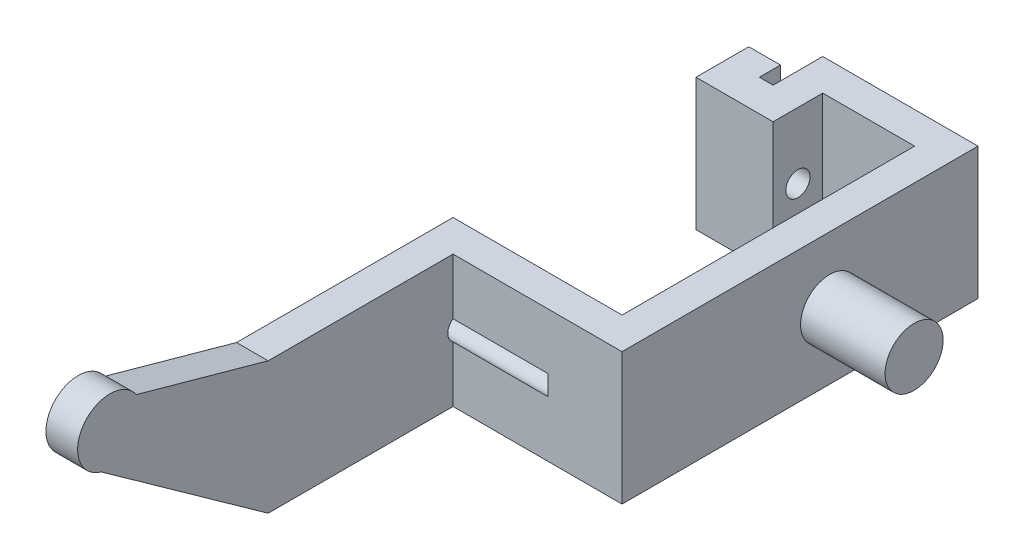
from build123d import *
from build123d.topology import SkipClean

# Parameters (mm, degrees)
EXTRUDE_1_DEPTH     = 12.5
SKETCH_2_R          = 1.15
CUT_EXTRUDE_1_DEPTH = 12
SKETCH_3_R          = 2.75
EXTRUDE_2_DEPTH     = 8
EXTRUDE_3_DEPTH     = 3
CUT_EXTRUDE_5_DEPTH = 3


with BuildPart() as part:
    # 草图1 → 凸台-拉伸1 (new body)
    with BuildSketch(Plane(origin=(0, 0, 0), x_dir=(1, 0, 0), z_dir=(0, 1, 0))):
        Polygon((0, 5), (0, 0), (7.3, 0), (7.3, 3), (7.3, 4.7), (16, 4.7), (16, 3), (16, 0), (16, -23), (0, -23), (0, -61), (3, -61), (3, -26), (19, -26), (19, 3), (19, 7.7), (4.3, 7.7), (4.3, 3), (3, 3), (3, 5), align=None)
    extrude(amount=EXTRUDE_1_DEPTH)

    # 草图2 → 切除-拉伸1 (cut)
    with BuildSketch(Plane.ZY):
        with Locations((25.35, 6.25)):
            Circle(SKETCH_2_R)
        with Locations((-2.35, 6.25)):
            Circle(SKETCH_2_R)
    extrude(amount=-CUT_EXTRUDE_1_DEPTH, mode=Mode.SUBTRACT)

    # 草图3 → 凸台-拉伸2 (add)
    with BuildSketch(Plane(origin=(19, 0, 0), x_dir=(0, 0, -1), z_dir=(1, 0, 0))):
        with Locations((-6.35, 6.25)):
            Circle(SKETCH_3_R)
    extrude(amount=EXTRUDE_2_DEPTH)

    # 草图4 → 凸台-拉伸3 (add)
    with BuildSketch(Plane(origin=(3, 0, 0), x_dir=(0, 0, -1), z_dir=(1, 0, 0))):
        with BuildLine():
            Line((-43.5, 12.5), (-55.974372634, 15.968285379))
            ThreePointArc((-55.974372634, 15.968285379), (-60.221329006, 16.746956372), (-61, 12.5))
            Line((-61, 12.5), (-43.5, 12.5))
        make_face()
    extrude(amount=-EXTRUDE_3_DEPTH)

    # 草图4<8> → 切除-拉伸5 (cut)
    with SkipClean():  # the faces are left unmerged after this step: merging them gives an invalid solid
        with BuildSketch(Plane(origin=(3, 0, 0), x_dir=(0, 0, -1), z_dir=(1, 0, 0))):
            with BuildLine():
                Line((-43.5, 0), (-52.25, 6.25))
                Line((-52.25, 6.25), (-59.312624964, 11.294732117))
                ThreePointArc((-59.312624964, 11.294732117), (-60.261770725, 11.749724518), (-61, 12.5))
                Line((-61, 12.5), (-61, 0))
                Line((-61, 0), (-43.5, 0))
            make_face()
        extrude(amount=-CUT_EXTRUDE_5_DEPTH, mode=Mode.SUBTRACT)


solid = part.part
